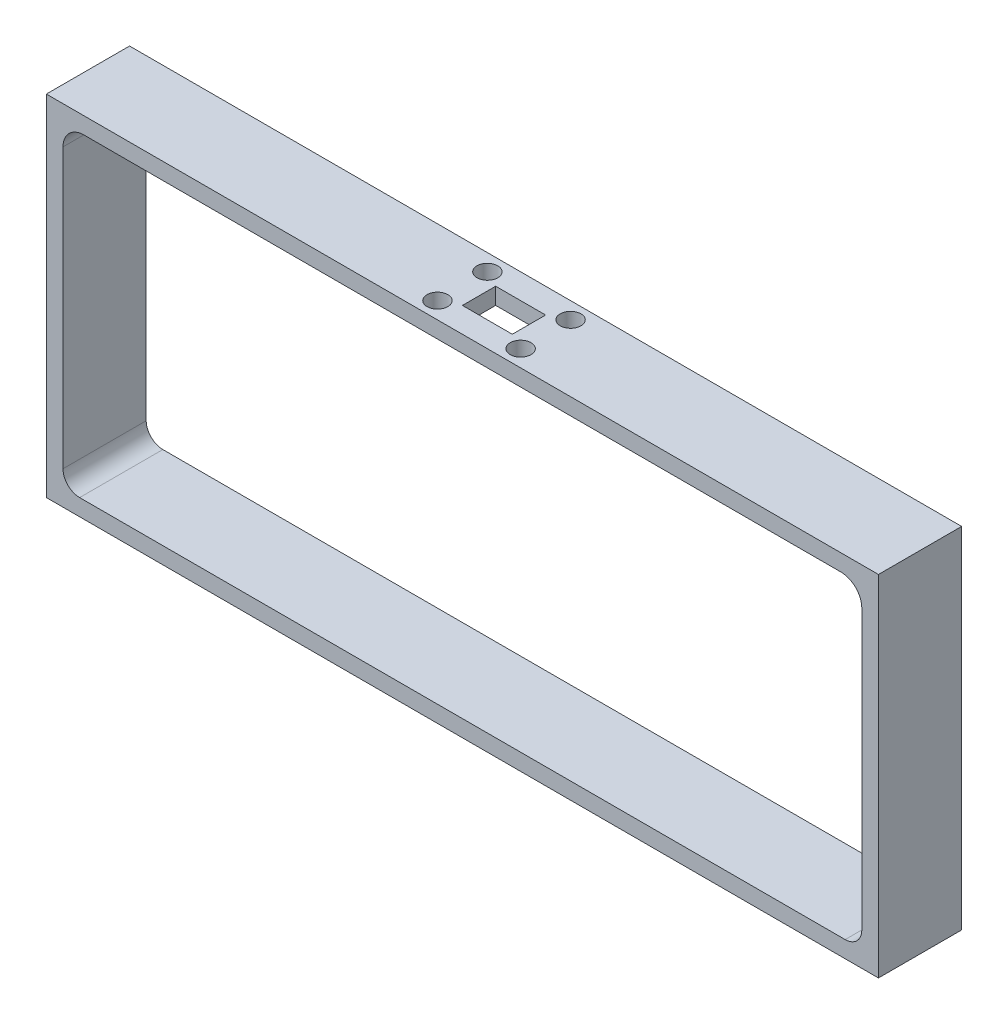
from build123d import *

# Parameters (mm, degrees)
SKETCH1_R           = 1.5875
SKETCH1_W           = 7.62
SKETCH1_H           = 5.08
BOSS_EXTRUDE1_DEPTH = 2.54
SKETCH2_W           = 2.54
SKETCH2_H           = 12.7
BOSS_EXTRUDE2_DEPTH = 50.8
SKETCH3_W           = 127
SKETCH3_H           = 12.7
BOSS_EXTRUDE3_DEPTH = 2.54
FILLET1_R           = 2.54
FILLET2_R           = 3.175


with BuildPart() as part:
    # Sketch1 → Boss-Extrude1 (new body)
    with BuildSketch(Plane(origin=(0, 0, 0), x_dir=(1, 0, 0), z_dir=(0, 1, 0))):
        Polygon((-63.5, 6.35), (-12.7, 6.35), (12.7, 6.35), (63.5, 6.35), (63.5, -6.35), (12.7, -6.35), (-12.7, -6.35), (-63.5, -6.35), align=None)
        with Locations((-6.35, 3.81)):
            Circle(SKETCH1_R, mode=Mode.SUBTRACT)
        with Locations((6.35, 3.81)):
            Circle(SKETCH1_R, mode=Mode.SUBTRACT)
        with Locations((6.35, -3.81)):
            Circle(SKETCH1_R, mode=Mode.SUBTRACT)
        with Locations((-6.35, -3.81)):
            Circle(SKETCH1_R, mode=Mode.SUBTRACT)
        Rectangle(SKETCH1_W, SKETCH1_H, mode=Mode.SUBTRACT)
    extrude(amount=BOSS_EXTRUDE1_DEPTH)

    # Sketch2 → Boss-Extrude2 (add)
    with BuildSketch(Plane.XZ):
        with Locations((-62.23, 0)):
            Rectangle(SKETCH2_W, SKETCH2_H)
        with Locations((62.23, 0)):
            Rectangle(SKETCH2_W, SKETCH2_H)
    extrude(amount=BOSS_EXTRUDE2_DEPTH)

    # Sketch3 → Boss-Extrude3 (add)
    with BuildSketch(Plane.XZ.offset(50.8)):
        Rectangle(SKETCH3_W, SKETCH3_H)
    extrude(amount=-BOSS_EXTRUDE3_DEPTH)

    # Fillet1
    fillet1_edges = [part.edges().sort_by_distance(p)[0] for p in [
        (-60.96, -48.26, 0),
        (60.96, -48.26, 0),
    ]]
    fillet(fillet1_edges, radius=FILLET1_R)

    # Fillet2
    fillet2_edges = [part.edges().sort_by_distance(p)[0] for p in [
        (-60.96, 0, 0),
        (60.96, 0, 0),
    ]]
    fillet(fillet2_edges, radius=FILLET2_R)


solid = part.part
